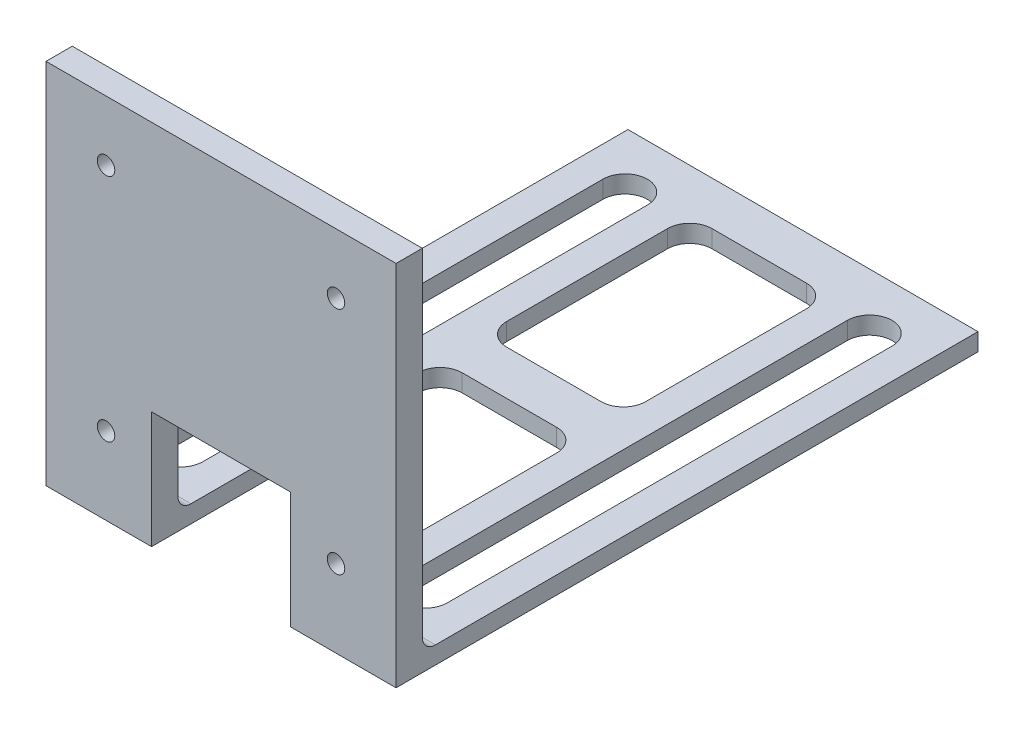
from build123d import *

# Parameters (mm, degrees)
SKETCH1_R           = 1
BOSS_EXTRUDE1_DEPTH = 3
SKETCH2_W           = 12.0625
SKETCH2_H           = 66.5
BOSS_EXTRUDE2_DEPTH = 2
FILLET1_R           = 1.5
SKETCH3_W           = 15.875
SKETCH3_H           = 5
SKETCH3_H_2         = 5.08
BOSS_EXTRUDE3_DEPTH = 2
FILLET2_R           = 2.54


with BuildPart() as part:
    # Sketch1 → Boss-Extrude1 (new body)
    with BuildSketch(Plane.XY):
        Polygon((-20, 20), (-20, -20), (-7.9375, -20), (-7.9375, -8.65), (7.9375, -8.65), (7.9375, -20), (20, -20), (20, 20), align=None)
        with Locations((-13.14, -13.14)):
            Circle(SKETCH1_R, mode=Mode.SUBTRACT)
        with Locations((13.14, -13.14)):
            Circle(SKETCH1_R, mode=Mode.SUBTRACT)
        with Locations((-13.14, 13.14)):
            Circle(SKETCH1_R, mode=Mode.SUBTRACT)
        with Locations((13.14, 13.14)):
            Circle(SKETCH1_R, mode=Mode.SUBTRACT)
    extrude(amount=BOSS_EXTRUDE1_DEPTH)

    # Sketch2 → Boss-Extrude2 (add)
    with BuildSketch(Plane.XZ.offset(20)):
        with Locations((-13.96875, -30.25)):
            Rectangle(SKETCH2_W, SKETCH2_H)
        with BuildLine():
            Line((-11.41605, -6.35), (-11.41605, -57.15))
            ThreePointArc((-11.41605, -57.15), (-13.96875, -59.7027), (-16.52145, -57.15))
            Line((-16.52145, -57.15), (-16.52145, -6.35))
            ThreePointArc((-16.52145, -6.35), (-13.96875, -3.7973), (-11.41605, -6.35))
        make_face(mode=Mode.SUBTRACT)
        with Locations((13.96875, -30.25)):
            Rectangle(SKETCH2_W, SKETCH2_H)
        with BuildLine():
            Line((11.41605, -6.35), (11.41605, -57.15))
            ThreePointArc((11.41605, -57.15), (13.96875, -59.7027), (16.52145, -57.15))
            Line((16.52145, -57.15), (16.52145, -6.35))
            ThreePointArc((16.52145, -6.35), (13.96875, -3.7973), (11.41605, -6.35))
        make_face(mode=Mode.SUBTRACT)
    extrude(amount=BOSS_EXTRUDE2_DEPTH)

    # Fillet1
    fillet1_edges = [part.edges().sort_by_distance(p)[0] for p in [
        (13.96875, -20, 0),
        (-13.96875, -20, 0),
    ]]
    fillet(fillet1_edges, radius=FILLET1_R)

    # Sketch3 → Boss-Extrude3 (add)
    with BuildSketch(Plane(origin=(0, -20, 0), x_dir=(1, 0, 0), z_dir=(0, 1, 0))):
        with Locations((0, 61)):
            Rectangle(SKETCH3_W, SKETCH3_H)
        with Locations((0, 32.5)):
            Rectangle(SKETCH3_W, SKETCH3_H_2)
    extrude(amount=-BOSS_EXTRUDE3_DEPTH)

    # Fillet2
    fillet2_edges = [part.edges().sort_by_distance(p)[0] for p in [
        (7.9375, -21, -58.5),
        (-7.9375, -21, -58.5),
        (7.9375, -21, -29.96),
        (7.9375, -21, -35.04),
        (-7.9375, -21, -35.04),
        (-7.9375, -21, -29.96),
    ]]
    fillet(fillet2_edges, radius=FILLET2_R)


solid = part.part
